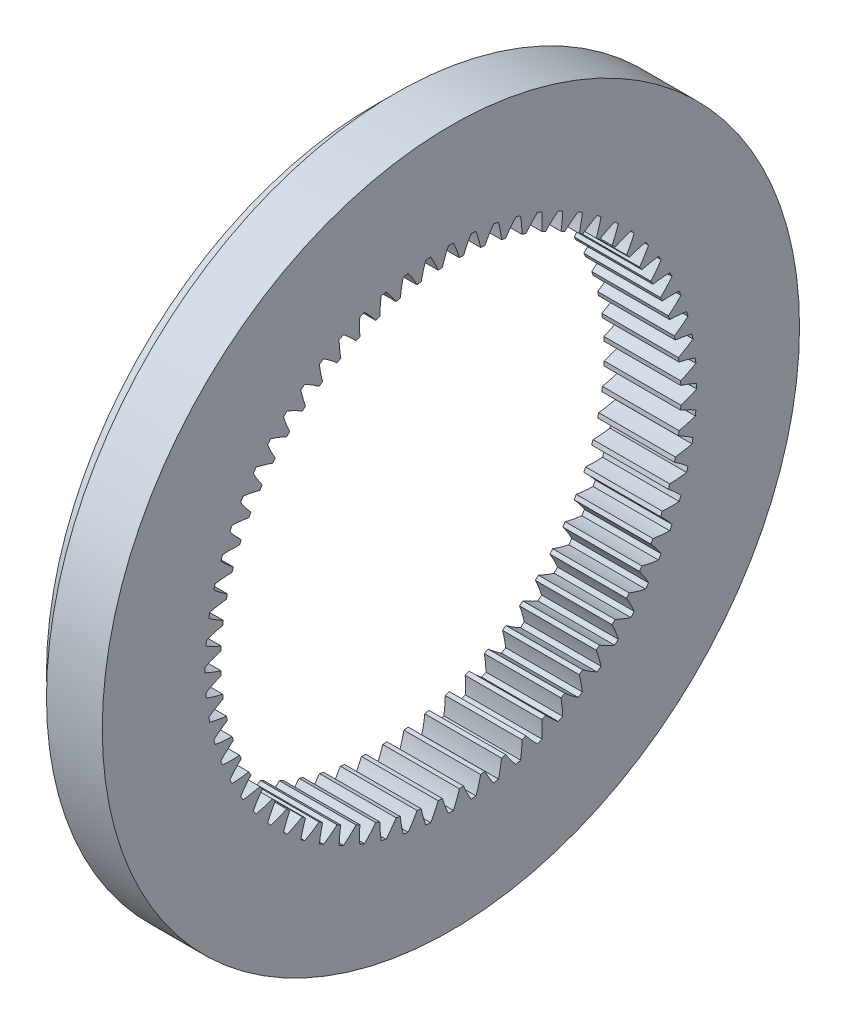
from build123d import *

# Parameters (mm, degrees)
BASPROSKE_W         = 11
BASPROSKE_H         = 14
TOOTHCUT_DEPTH      = 68.372101051
TEETHCUTS_COUNT     = 68
TEETHCUTS_ANGLE     = 354.705882353
SKETCH1_R           = 50
SKETCH1_R_2         = 47
BOSS_EXTRUDE1_DEPTH = 8


with BuildPart() as part:
    # BasProSke → Base-Revolve (revolve)
    with BuildSketch(Plane(origin=(0, 0, 0), x_dir=(1, 0, 0), z_dir=(0, 1, 0))):
        with Locations((5.5, 40)):
            Rectangle(BASPROSKE_W, BASPROSKE_H)
    revolve(axis=Axis((-10, 0, 0), (1, 0, 0)))

    # TooCutSke → ToothCut (cut, through all)
    with BuildSketch(Plane(origin=(0, 0, 0), x_dir=(0, 0, -1), z_dir=(1, 0, 0))):
        with BuildLine():
            ThreePointArc((1.226521152, 32.951781303), (0.832509023, 34.116254131), (0.355375272, 35.249208635))
            ThreePointArc((0.355375272, 35.249208635), (0, 35.251), (-0.355375272, 35.249208635))
            ThreePointArc((-0.355375272, 35.249208635), (-0.832509023, 34.116254131), (-1.226521152, 32.951781303))
            ThreePointArc((-1.226521152, 32.951781303), (0, 32.9746), (1.226521152, 32.951781303))
        make_face()
    toothcut = extrude(amount=TOOTHCUT_DEPTH, mode=Mode.SUBTRACT)

    # TeethCuts: ToothCut ×68 about axis
    teethcuts_axis = Axis((-10, 0, 0), (1, 0, 0))
    for i in range(1, TEETHCUTS_COUNT):
        add(toothcut.rotate(teethcuts_axis, i * TEETHCUTS_ANGLE / (TEETHCUTS_COUNT - 1)), mode=Mode.SUBTRACT)

    # Sketch1 → Boss-Extrude1 (add)
    with BuildSketch(Plane(origin=(11, 0, 0), x_dir=(0, 0, -1), z_dir=(1, 0, 0))):
        Circle(SKETCH1_R)
        Circle(SKETCH1_R_2, mode=Mode.SUBTRACT)
    extrude(amount=-BOSS_EXTRUDE1_DEPTH)


solid = part.part
